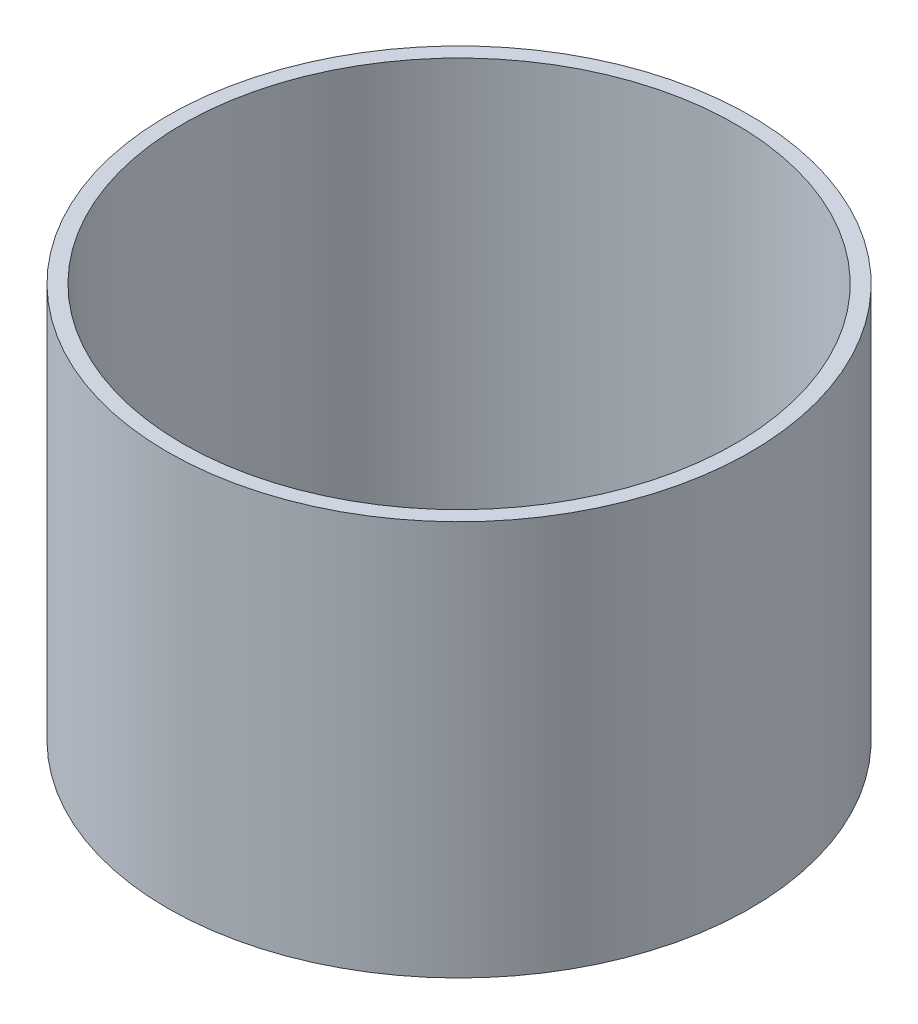
from build123d import *

# Parameters (mm, degrees)
SKETCH1_R           = 93.6625
SKETCH1_R_2         = 88.9
BOSS_EXTRUDE1_DEPTH = 63.5


with BuildPart() as part:
    # Sketch1 → Boss-Extrude1 (new body, symmetric)
    with BuildSketch(Plane(origin=(0, 0, 0), x_dir=(1, 0, 0), z_dir=(0, 1, 0))):
        Circle(SKETCH1_R)
        Circle(SKETCH1_R_2, mode=Mode.SUBTRACT)
    extrude(amount=BOSS_EXTRUDE1_DEPTH, both=True)


solid = part.part
